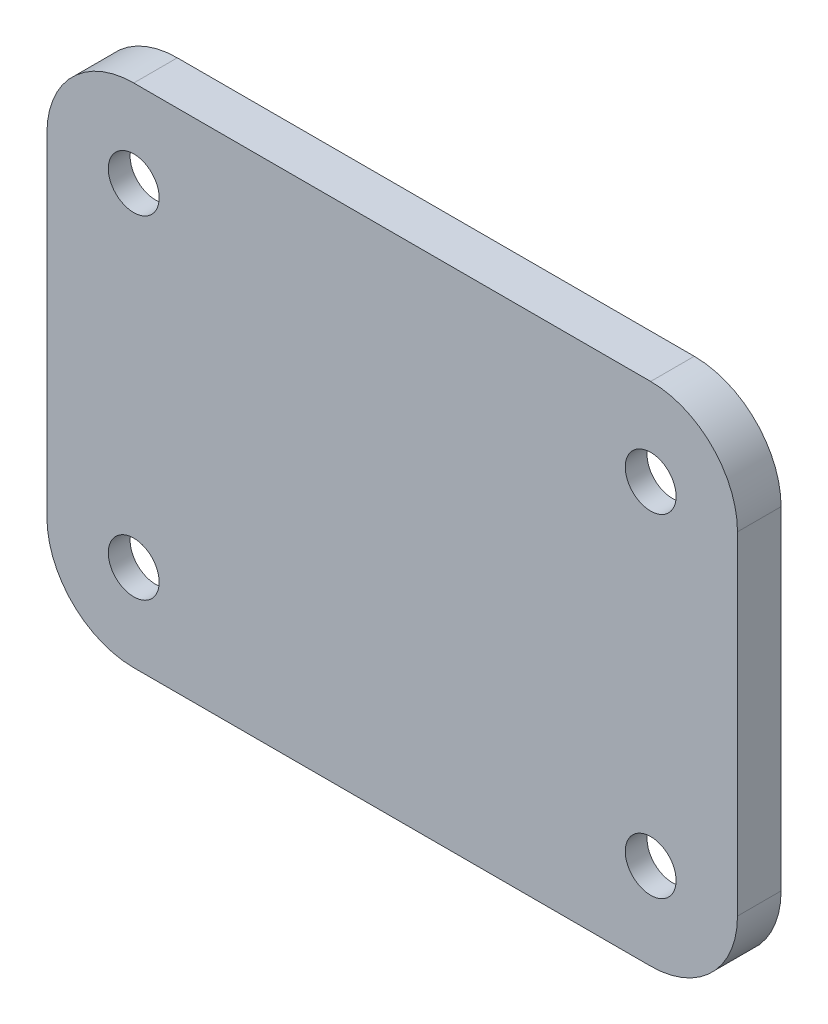
from build123d import *

# Parameters (mm, degrees)
SKETCH1_R           = 1.75
BOSS_EXTRUDE1_DEPTH = 1.5
BOSS_EXTRUDE2_DEPTH = 1.5
SKETCH3_W           = 26.625
SKETCH3_H           = 13.95
CUT_EXTRUDE1_DEPTH  = 0.5


with BuildPart() as part:
    # Sketch1 → Boss-Extrude1 (new body)
    with BuildSketch(Plane.XY):
        with BuildLine():
            ThreePointArc((23.7625, 11.45), (22.012463018, 15.674963018), (17.7875, 17.425))
            Line((17.7875, 17.425), (-17.7875, 17.425))
            ThreePointArc((-17.7875, 17.425), (-22.012463018, 15.674963018), (-23.7625, 11.45))
            Line((-23.7625, 11.45), (-23.7625, -11.45))
            ThreePointArc((-23.7625, -11.45), (-22.012463018, -15.674963018), (-17.7875, -17.425))
            Line((-17.7875, -17.425), (17.7875, -17.425))
            ThreePointArc((17.7875, -17.425), (22.012463018, -15.674963018), (23.7625, -11.45))
            Line((23.7625, -11.45), (23.7625, 11.45))
        make_face()
        with Locations((-17.7875, -11.45)):
            Circle(SKETCH1_R, mode=Mode.SUBTRACT)
        with Locations((17.7875, -11.45)):
            Circle(SKETCH1_R, mode=Mode.SUBTRACT)
        with Locations((17.7875, 11.45)):
            Circle(SKETCH1_R, mode=Mode.SUBTRACT)
        with Locations((-17.7875, 11.45)):
            Circle(SKETCH1_R, mode=Mode.SUBTRACT)
    extrude(amount=BOSS_EXTRUDE1_DEPTH)

    # Sketch2 → Boss-Extrude2 (add)
    with BuildSketch(Plane(origin=(0, 0, 0), x_dir=(-1, 0, 0), z_dir=(0, 0, -1))):
        with BuildLine():
            Line((-17.7875, -17.425), (17.7875, -17.425))
            ThreePointArc((17.7875, -17.425), (22.012463018, -15.674963018), (23.7625, -11.45))
            Line((23.7625, -11.45), (23.7625, 11.45))
            ThreePointArc((23.7625, 11.45), (22.012463018, 15.674963018), (17.7875, 17.425))
            Line((17.7875, 17.425), (-17.7875, 17.425))
            ThreePointArc((-17.7875, 17.425), (-22.012463018, 15.674963018), (-23.7625, 11.45))
            Line((-23.7625, 11.45), (-23.7625, -11.45))
            ThreePointArc((-23.7625, -11.45), (-22.012463018, -15.674963018), (-17.7875, -17.425))
        make_face()
        with BuildLine():
            Line((17.7875, 15.925), (-17.7875, 15.925))
            ThreePointArc((-17.7875, 15.925), (-20.951802846, 14.614302846), (-22.2625, 11.45))
            Line((-22.2625, 11.45), (-22.2625, -11.45))
            ThreePointArc((-22.2625, -11.45), (-20.951802846, -14.614302846), (-17.7875, -15.925))
            Line((-17.7875, -15.925), (17.7875, -15.925))
            ThreePointArc((17.7875, -15.925), (20.951802846, -14.614302846), (22.2625, -11.45))
            Line((22.2625, -11.45), (22.2625, 11.45))
            ThreePointArc((22.2625, 11.45), (20.951802846, 14.614302846), (17.7875, 15.925))
        make_face(mode=Mode.SUBTRACT)
    extrude(amount=BOSS_EXTRUDE2_DEPTH)

    # Sketch3 → Cut-Extrude1 (cut)
    with BuildSketch(Plane(origin=(0, 0, 0), x_dir=(-1, 0, 0), z_dir=(0, 0, -1))):
        with BuildLine():
            Line((-17.7875, 6.975), (-13.3125, 6.975))
            Line((-13.3125, 6.975), (-13.3125, 11.45))
            ThreePointArc((-13.3125, 11.45), (-14.623197154, 8.285697154), (-17.7875, 6.975))
        make_face()
        Polygon((-17.787500036, -6.975), (-13.3125, -6.975), (-13.3125, 6.975), (-17.7875, 6.975), (-22.2625, 6.975), (-22.2625, -6.975), align=None)
        Polygon((-13.3125, 6.975), (13.3125, 6.975), (13.3125, 11.45), (13.3125, 15.925), (-13.3125, 15.925), (-13.3125, 11.45), align=None)
        with BuildLine():
            Line((13.3125, 6.975), (17.7875, 6.975))
            ThreePointArc((17.7875, 6.975), (14.623197154, 8.285697154), (13.3125, 11.45))
            Line((13.3125, 11.45), (13.3125, 6.975))
        make_face()
        Polygon((17.7875, -6.975), (22.2625, -6.975), (22.2625, 6.975), (17.7875, 6.975), (13.3125, 6.975), (13.3125, -6.975), align=None)
        with BuildLine():
            ThreePointArc((13.3125, -11.45), (14.623197154, -8.285697154), (17.7875, -6.975))
            Line((17.7875, -6.975), (13.3125, -6.975))
            Line((13.3125, -6.975), (13.3125, -11.45))
        make_face()
        Polygon((13.3125, -11.45), (13.3125, -6.975), (-13.3125, -6.975), (-13.3125, -11.45), (-13.3125, -15.925), (13.3125, -15.925), align=None)
        Rectangle(SKETCH3_W, SKETCH3_H)
    extrude(amount=-CUT_EXTRUDE1_DEPTH, mode=Mode.SUBTRACT)


solid = part.part
